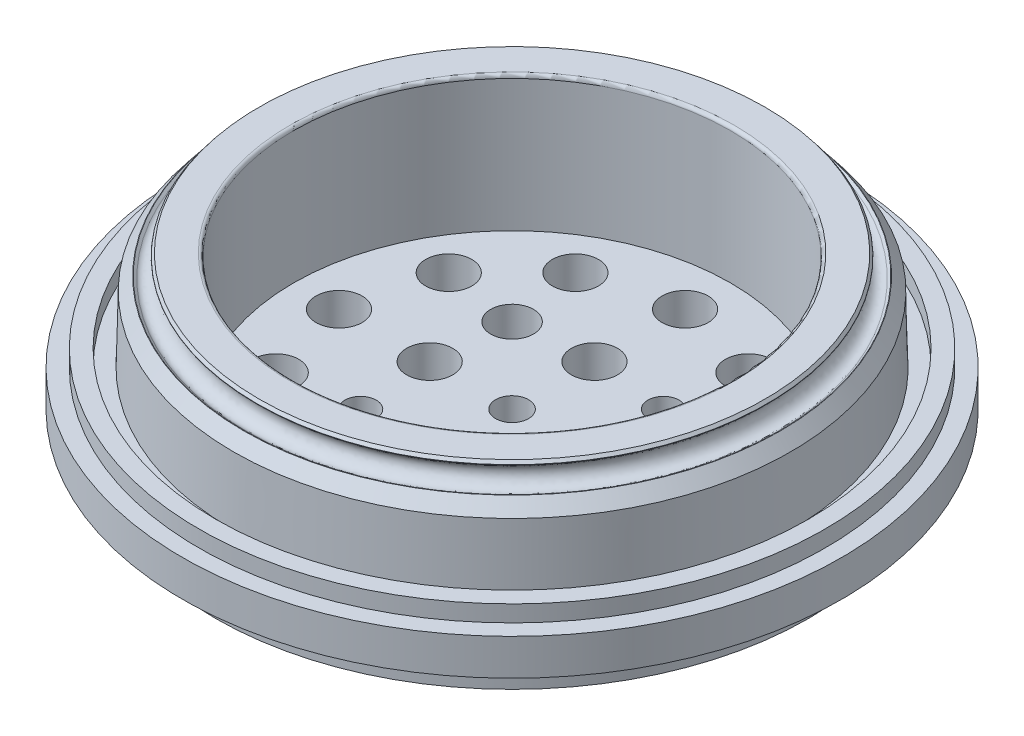
from build123d import *

# Parameters (mm, degrees)
FILLET1_R           = 1
SKETCH3_R           = 90
BOSS_EXTRUDE1_DEPTH = 10
SKETCH2_R           = 7
SKETCH2_R_2         = 5
SKETCH2_R_3         = 6.5
SKETCH2_R_4         = 4.7625
CUT_EXTRUDE1_DEPTH  = 10
FILLET2_R           = 0.1


with BuildPart() as part:
    # Sketch1 → Revolve1 (revolve)
    with BuildSketch(Plane.XY):
        with BuildLine():
            Line((76.75, 40.74810371), (66.326451616, 40.74810371))
            Line((66.326451616, 40.74810371), (66.326451616, -0.262378674))
            Line((66.326451616, -0.262378674), (100, -0.262378674))
            Line((100, -0.262378674), (100, 10.737621326))
            Line((100, 10.737621326), (95, 10.737621326))
            Line((95, 10.737621326), (95, 15.737621326))
            Line((95, 15.737621326), (89.9, 15.737621326))
            Line((89.9, 15.737621326), (89.9, 10.737621326))
            Line((89.9, 10.737621326), (84.99, 10.737621326))
            Line((84.99, 10.737621326), (84.5, 30.749659223))
            Line((84.5, 30.749659223), (81.364088934, 34.79536667))
            Line((81.364088934, 34.79536667), (80.521555676, 34.142301811))
            add(Edge.make_bspline(
                [(76.631347555, 39.161144384), (74.517110723, 37.522355923), (76.462214784, 35.012934637), (78.407318844, 32.50351335), (80.521555676, 34.142301811)],
                knots=[0, 0, 0, 1.570796327, 1.570796327, 3.141592654, 3.141592654, 3.141592654], degree=2, weights=[1, 0.707106781, 1, 0.707106781, 1]))
            Line((76.631347555, 39.161144384), (77.473880812, 39.814209243))
            Line((77.473880812, 39.814209243), (76.75, 40.74810371))
        make_face()
    revolve(axis=Axis((0, 0, 0), (0, 1, 0)))

    # Fillet1
    fillet1_edges = [part.edges().sort_by_distance(p)[0] for p in [
        (-66.326451616, 40.74810371, 0),
    ]]
    fillet(fillet1_edges, radius=FILLET1_R)

    # Sketch3 → Boss-Extrude1 (add)
    with BuildSketch(Plane.XZ.offset(0.262378674)):
        Circle(SKETCH3_R)
    extrude(amount=BOSS_EXTRUDE1_DEPTH)

    # Sketch2 → Cut-Extrude1 (cut)
    with BuildSketch(Plane.XZ.offset(0.262378674)):
        with Locations((0, 52.5)):
            Circle(SKETCH2_R)
        with Locations((0, 25)):
            Circle(SKETCH2_R)
        Circle(SKETCH2_R_2)
        with Locations((26.25, 45.466333699)):
            Circle(SKETCH2_R)
        with Locations((45.466333699, 26.25)):
            Circle(SKETCH2_R)
        with Locations((52.5, 0)):
            Circle(SKETCH2_R)
        with Locations((45.466333699, -26.25)):
            Circle(SKETCH2_R)
        with Locations((26.25, -45.466333699)):
            Circle(SKETCH2_R)
        with Locations((0, -52.5)):
            Circle(SKETCH2_R)
        with Locations((-26.25, -45.466333699)):
            Circle(SKETCH2_R)
        with Locations((-45.466333699, -26.25)):
            Circle(SKETCH2_R)
        with Locations((-52.5, 0)):
            Circle(SKETCH2_R)
        with Locations((-45.466333699, 26.25)):
            Circle(SKETCH2_R)
        with Locations((-26.25, 45.466333699)):
            Circle(SKETCH2_R)
        with Locations((25, 0)):
            Circle(SKETCH2_R)
        with Locations((0, -25)):
            Circle(SKETCH2_R)
        with Locations((-25, 0)):
            Circle(SKETCH2_R)
        with Locations((22.980970389, 22.980970389)):
            Circle(SKETCH2_R_3)
        with Locations((-22.980970389, -22.980970389)):
            Circle(SKETCH2_R_3)
        with Locations((-22.980970389, 22.980970389)):
            Circle(SKETCH2_R_4)
        with Locations((22.980970389, -22.980970389)):
            Circle(SKETCH2_R_4)
    extrude(amount=CUT_EXTRUDE1_DEPTH, mode=Mode.SUBTRACT)

    # Fillet2
    fillet2_edges = [part.edges().sort_by_distance(p)[0] for p in [
        (-81.364088934, 34.79536667, 0),
        (-77.473880812, 39.814209243, 0),
    ]]
    fillet(fillet2_edges, radius=FILLET2_R)


solid = part.part
